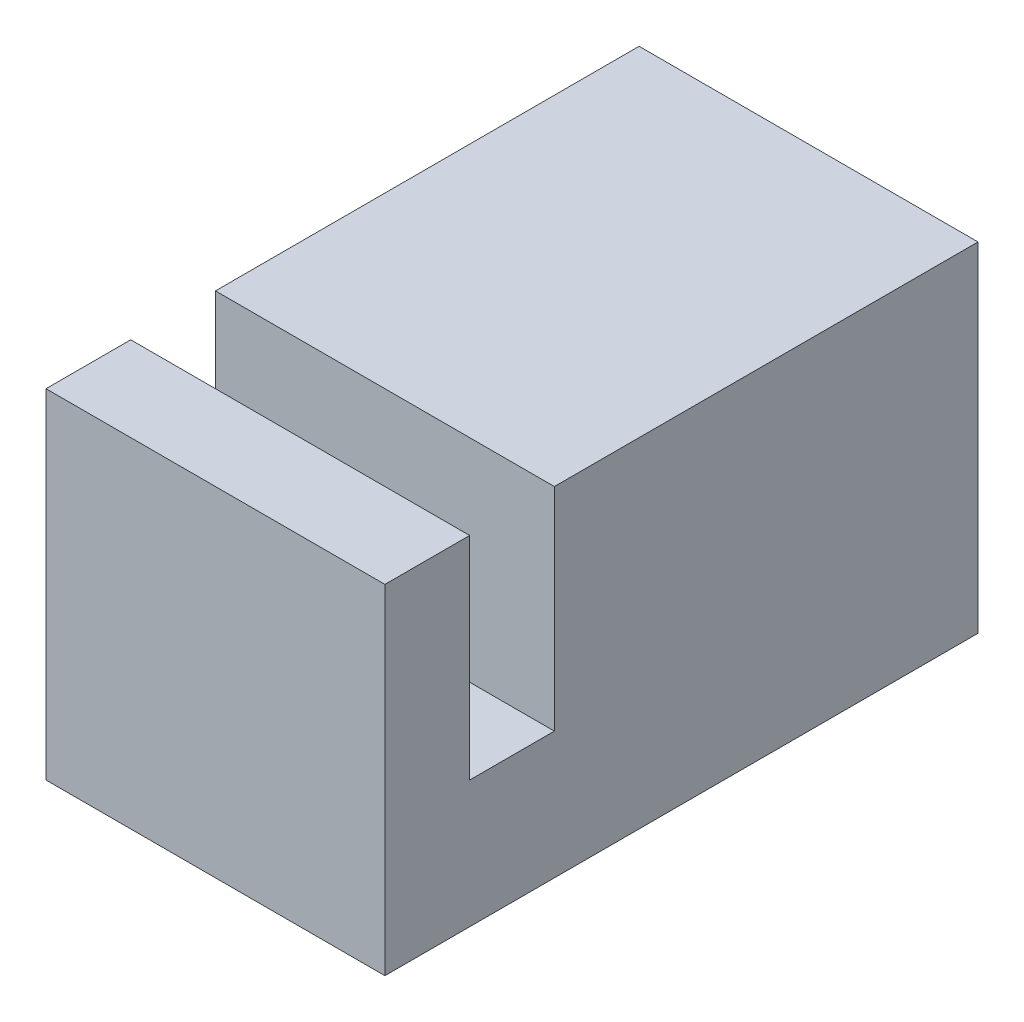
from build123d import *

# Parameters (mm, degrees)
SZKIC1_W                    = 8
SZKIC1_H                    = 8
DODANIE_WYCI_GNI_CIE1_DEPTH = 14
WYTNIJ_WYCI_GNI_CIE1_DEPTH  = 5
SZKIC3_R                    = 1.375
WYTNIJ_WYCI_GNI_CIE2_DEPTH  = 9


with BuildPart() as part:
    # Szkic1 → Dodanie-wyciągnięcie1 (new body)
    with BuildSketch(Plane.XY):
        with Locations((4, 4)):
            Rectangle(SZKIC1_W, SZKIC1_H)
    extrude(amount=DODANIE_WYCI_GNI_CIE1_DEPTH)

    # Szkic2 → Wytnij-wyciągnięcie1 (cut)
    with BuildSketch(Plane(origin=(0, 8, 0), x_dir=(1, 0, 0), z_dir=(0, 1, 0))):
        Polygon((0, -10), (5, -10), (8, -10), (8, -12), (5, -12), (0, -12), align=None)
    extrude(amount=-WYTNIJ_WYCI_GNI_CIE1_DEPTH, mode=Mode.SUBTRACT)

    # Szkic3 → Wytnij-wyciągnięcie2 (cut)
    with BuildSketch(Plane(origin=(0, 0, 0), x_dir=(-1, 0, 0), z_dir=(0, 0, -1))):
        with Locations((-4, 4)):
            Circle(SZKIC3_R)
    extrude(amount=-WYTNIJ_WYCI_GNI_CIE2_DEPTH, mode=Mode.SUBTRACT)


solid = part.part
